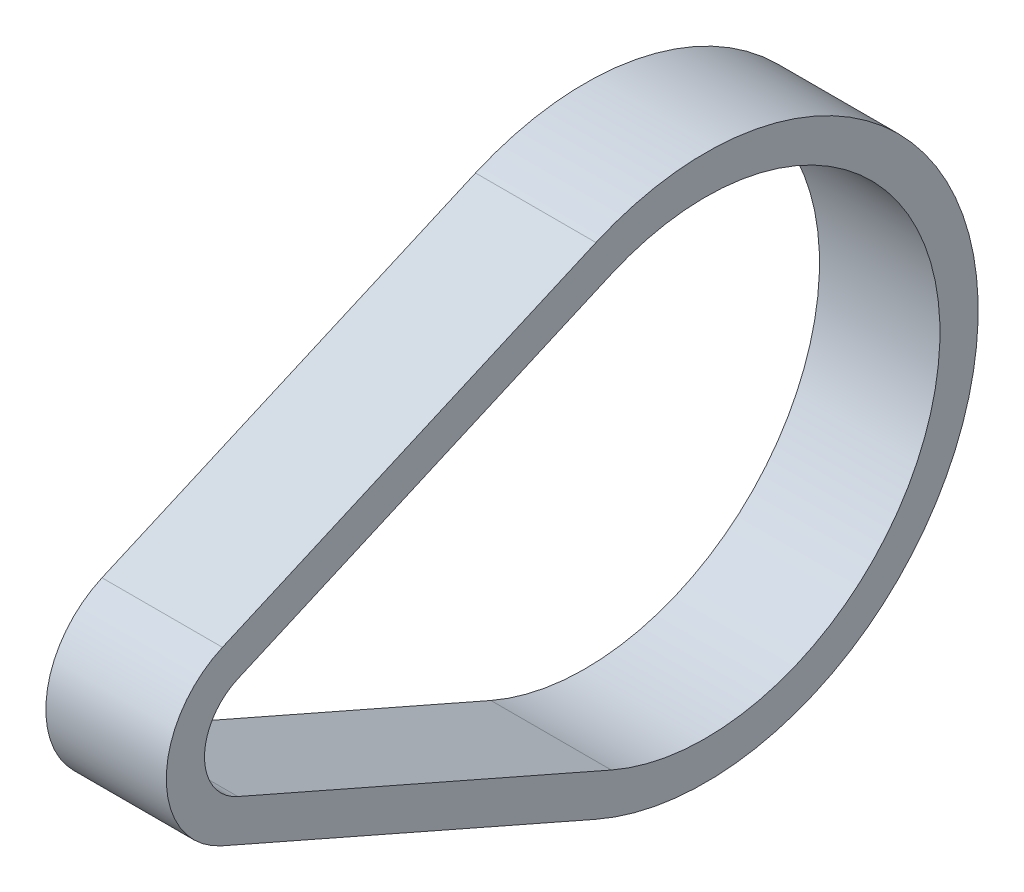
from build123d import *

# Parameters (mm, degrees)
BOSS_EXTRUDE1_DEPTH = 7.5


with BuildPart() as part:
    # Sketch1 → Boss-Extrude1 (new body, symmetric)
    with BuildSketch(Plane(origin=(0, 0, 0), x_dir=(0, 0, -1), z_dir=(1, 0, 0))):
        with BuildLine():
            Line((-4.69436879, 10.705021855), (41.82152471, 31.103182795))
            ThreePointArc((41.82152471, 31.103182795), (89.42324, 0), (41.82152471, -31.103182795))
            Line((41.82152471, -31.103182795), (-4.69436879, -10.705021855))
            ThreePointArc((-4.69436879, -10.705021855), (-11.68908, 0), (-4.69436879, 10.705021855))
        make_face()
        with BuildLine():
            Line((-2.78173483, 6.343458192), (43.734158669, 26.741619132))
            ThreePointArc((43.734158669, 26.741619132), (84.66074, 0), (43.734158669, -26.741619132))
            Line((43.734158669, -26.741619132), (-2.78173483, -6.343458192))
            ThreePointArc((-2.78173483, -6.343458192), (-6.92658, 0), (-2.78173483, 6.343458192))
        make_face(mode=Mode.SUBTRACT)
    extrude(amount=BOSS_EXTRUDE1_DEPTH, both=True)


solid = part.part
